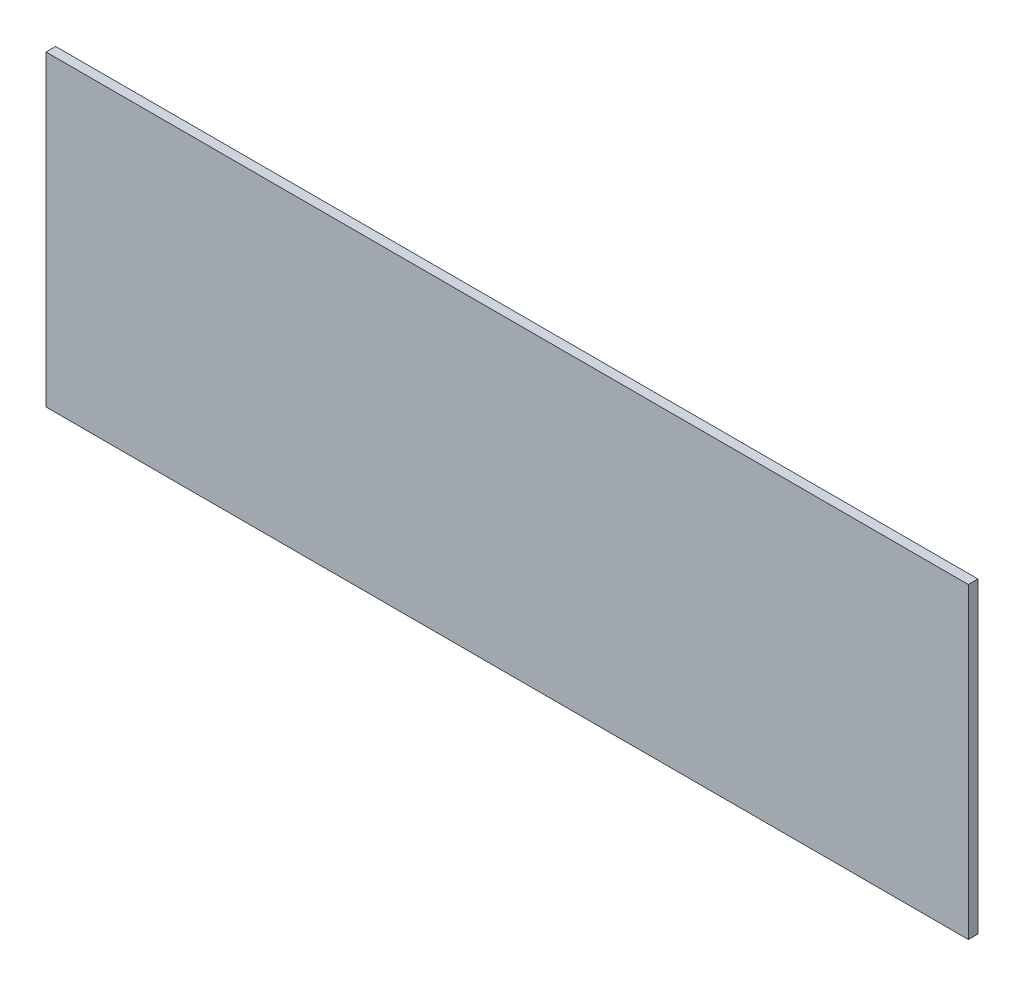
from build123d import *

# Parameters (mm, degrees)
SKETCH1_W           = 304.8
SKETCH1_H           = 101.6
BOSS_EXTRUDE1_DEPTH = 3.175


with BuildPart() as part:
    # Sketch1 → Boss-Extrude1 (new body)
    with BuildSketch(Plane.XY):
        Rectangle(SKETCH1_W, SKETCH1_H)
    extrude(amount=BOSS_EXTRUDE1_DEPTH)


solid = part.part
